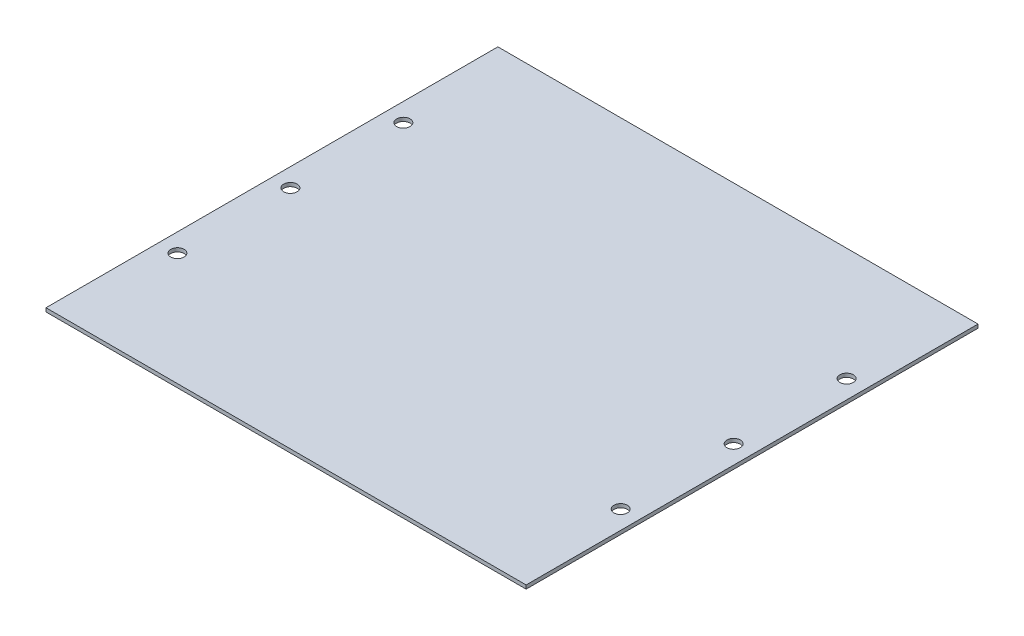
from build123d import *

# Parameters (mm, degrees)
SKETCH4_W           = 323.85
SKETCH4_H           = 304.8
SKETCH4_R           = 4.519763285
BOSS_EXTRUDE3_DEPTH = 2.4765


with BuildPart() as part:
    # Sketch4 → Boss-Extrude3 (new body)
    with BuildSketch(Plane(origin=(0, 0, 0), x_dir=(1, 0, 0), z_dir=(0, 1, 0))):
        with Locations((-143.408499065, -304.088133901)):
            Rectangle(SKETCH4_W, SKETCH4_H)
        with Locations((-292.887499065, -227.888133901)):
            Circle(SKETCH4_R, mode=Mode.SUBTRACT)
        with Locations((-292.887499065, -304.088133901)):
            Circle(SKETCH4_R, mode=Mode.SUBTRACT)
        with Locations((-292.887499065, -380.288133901)):
            Circle(SKETCH4_R, mode=Mode.SUBTRACT)
        with Locations((6.070500935, -227.888133901)):
            Circle(SKETCH4_R, mode=Mode.SUBTRACT)
        with Locations((6.070500935, -304.088133901)):
            Circle(SKETCH4_R, mode=Mode.SUBTRACT)
        with Locations((6.070500935, -380.288133901)):
            Circle(SKETCH4_R, mode=Mode.SUBTRACT)
    extrude(amount=BOSS_EXTRUDE3_DEPTH)


solid = part.part
